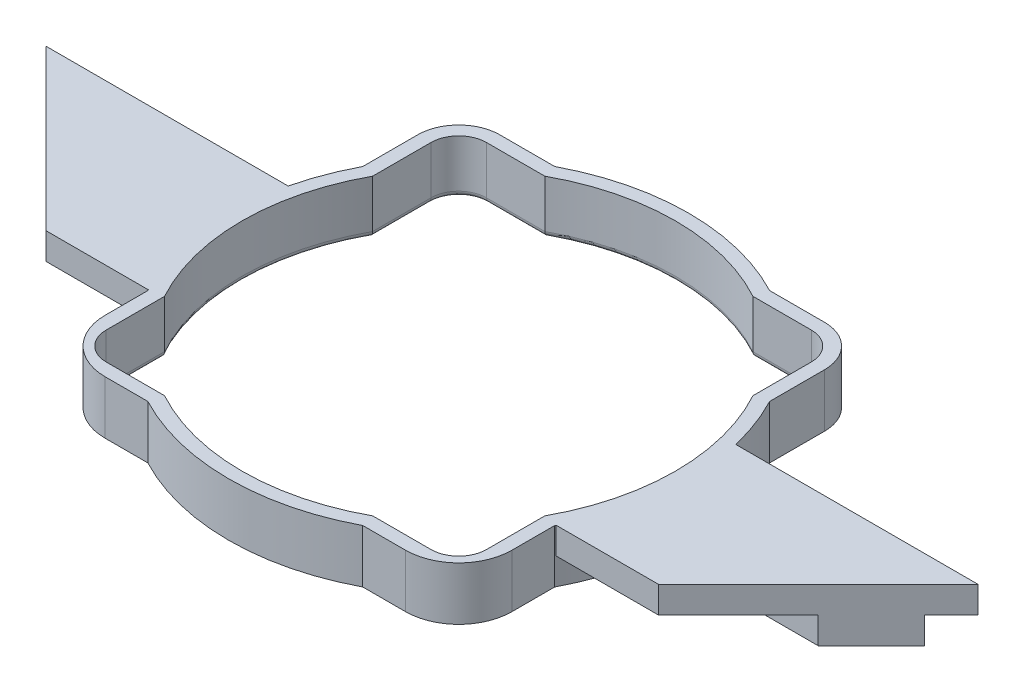
from build123d import *

# Parameters (mm, degrees)
SKETCH1_W           = 254
SKETCH1_H           = 152.4
BOSS_EXTRUDE1_DEPTH = 12.7
SKETCH4_OUTSIDE_W   = 315.296
SKETCH4_OUTSIDE_H   = 213.696
CUT_EXTRUDE1_DEPTH  = 13.7
BOSS_EXTRUDE2_DEPTH = 6.35
BOSS_EXTRUDE3_START = 6.35
BOSS_EXTRUDE3_DEPTH = 6.35
FILLET1_R           = 1.27
CUT_EXTRUDE3_DEPTH  = 13.7000001


with BuildPart() as part:
    # Sketch1 → Boss-Extrude1 (new body)
    with BuildSketch(Plane(origin=(0, 0, 0), x_dir=(1, 0, 0), z_dir=(0, 1, 0))):
        Rectangle(SKETCH1_W, SKETCH1_H)
    extrude(amount=BOSS_EXTRUDE1_DEPTH)

    # Sketch4 outside → Cut-Extrude1 (cut, through all)
    with BuildSketch(Plane.XZ):
        Rectangle(SKETCH4_OUTSIDE_W, SKETCH4_OUTSIDE_H)
        with BuildLine():
            Line((48.514, 25.621286072), (48.514, 38.735))
            ThreePointArc((48.514, 38.735), (45.649797213, 45.649797213), (38.735, 48.514))
            Line((38.735, 48.514), (25.621286072, 48.514))
            ThreePointArc((25.621286072, 48.514), (0, 54.864), (-25.621286072, 48.514))
            Line((-25.621286072, 48.514), (-38.735, 48.514))
            ThreePointArc((-38.735, 48.514), (-45.649797213, 45.649797213), (-48.514, 38.735))
            Line((-48.514, 38.735), (-48.514, 25.621286072))
            ThreePointArc((-48.514, 25.621286072), (-54.864, 0), (-48.514, -25.621286072))
            Line((-48.514, -25.621286072), (-48.514, -38.735))
            ThreePointArc((-48.514, -38.735), (-45.649797213, -45.649797213), (-38.735, -48.514))
            Line((-38.735, -48.514), (-25.621286072, -48.514))
            ThreePointArc((-25.621286072, -48.514), (0, -54.864), (25.621286072, -48.514))
            Line((25.621286072, -48.514), (38.735, -48.514))
            ThreePointArc((38.735, -48.514), (45.649797213, -45.649797213), (48.514, -38.735))
            Line((48.514, -38.735), (48.514, -25.621286072))
            ThreePointArc((48.514, -25.621286072), (54.864, 0), (48.514, 25.621286072))
        make_face(mode=Mode.SUBTRACT)
        with BuildLine():
            Line((45.339, 24.821921763), (45.339, 38.735))
            ThreePointArc((45.339, 38.735), (43.404733183, 43.404733183), (38.735, 45.339))
            Line((38.735, 45.339), (24.821921763, 45.339))
            ThreePointArc((24.821921763, 45.339), (0, 51.689), (-24.821921763, 45.339))
            Line((-24.821921763, 45.339), (-38.735, 45.339))
            ThreePointArc((-38.735, 45.339), (-43.404733183, 43.404733183), (-45.339, 38.735))
            Line((-45.339, 38.735), (-45.339, 24.821921763))
            ThreePointArc((-45.339, 24.821921763), (-51.689, 0), (-45.339, -24.821921763))
            Line((-45.339, -24.821921763), (-45.339, -38.735))
            ThreePointArc((-45.339, -38.735), (-43.404733183, -43.404733183), (-38.735, -45.339))
            Line((-38.735, -45.339), (-24.821921763, -45.339))
            ThreePointArc((-24.821921763, -45.339), (0, -51.689), (24.821921763, -45.339))
            Line((24.821921763, -45.339), (38.735, -45.339))
            ThreePointArc((38.735, -45.339), (43.404733183, -43.404733183), (45.339, -38.735))
            Line((45.339, -38.735), (45.339, -24.821921763))
            ThreePointArc((45.339, -24.821921763), (51.689, 0), (45.339, 24.821921763))
        make_face()
    extrude(amount=-CUT_EXTRUDE1_DEPTH, mode=Mode.SUBTRACT)

    # Sketch5 → Boss-Extrude2 (add)
    with BuildSketch(Plane(origin=(0, 0, 0), x_dir=(1, 0, 0), z_dir=(0, 1, 0))):
        with BuildLine():
            Line((54.495284163, 6.35), (104.775, 6.35))
            Line((104.775, 6.35), (92.075, -6.35))
            Line((92.075, -6.35), (54.495284163, -6.35))
            ThreePointArc((54.495284163, -6.35), (54.864, 0), (54.495284163, 6.35))
        make_face()
        with BuildLine():
            Line((-92.075, -6.35), (-54.495284163, -6.35))
            ThreePointArc((-54.495284163, -6.35), (-54.864, 0), (-54.495284163, 6.35))
            Line((-54.495284163, 6.35), (-104.775, 6.35))
            Line((-104.775, 6.35), (-92.075, -6.35))
        make_face()
    extrude(amount=BOSS_EXTRUDE2_DEPTH)

    # Sketch6 → Boss-Extrude3 (add)
    with BuildSketch(Plane(origin=(0, 0, 0), x_dir=(1, 0, 0), z_dir=(0, 1, 0)).offset(BOSS_EXTRUDE3_START)):
        with BuildLine():
            Line((53.373855922, 12.7), (111.125, 12.7))
            Line((111.125, 12.7), (73.025, -25.4))
            Line((73.025, -25.4), (48.630222043, -25.4))
            ThreePointArc((48.630222043, -25.4), (54.443644996, -6.778496559), (53.373855922, 12.7))
        make_face()
        with BuildLine():
            Line((-73.025, -25.4), (-48.630222043, -25.4))
            ThreePointArc((-48.630222043, -25.4), (-54.443644996, -6.778496559), (-53.373855922, 12.7))
            Line((-53.373855922, 12.7), (-111.125, 12.7))
            Line((-111.125, 12.7), (-73.025, -25.4))
        make_face()
    extrude(amount=BOSS_EXTRUDE3_DEPTH)

    # Fillet1
    fillet1_edges = [part.edges().sort_by_distance(p)[0] for p in [
        (51.689, 0, 0),
        (45.339, 0, 31.778460881),
        (43.404733183, 0, 43.404733183),
        (31.778460881, 0, 45.339),
        (0, 0, 51.689),
        (-31.778460881, 0, 45.339),
        (-43.404733183, 0, 43.404733183),
        (-45.339, 0, 31.778460881),
        (-51.689, 0, 0),
        (-45.339, 0, -31.778460881),
        (-43.404733183, 0, -43.404733183),
        (-31.778460881, 0, -45.339),
        (0, 0, -51.689),
        (31.778460881, 0, -45.339),
        (43.404733183, 0, -43.404733183),
        (45.339, 0, -31.778460881),
    ]]
    fillet(fillet1_edges, radius=FILLET1_R)

    # Sketch9 → Cut-Extrude3 (cut, through all)
    with BuildSketch(Plane(origin=(0, 12.7, 0), x_dir=(1, 0, 0), z_dir=(0, 1, 0))):
        with BuildLine():
            Line((38.735, -48.514), (35.814, -48.514))
            ThreePointArc((35.814, -48.514), (44.794256121, -44.794256121), (48.514, -35.814))
            Line((48.514, -35.814), (48.514, -38.735))
            ThreePointArc((48.514, -38.735), (45.649797213, -45.649797213), (38.735, -48.514))
        make_face()
        with BuildLine():
            Line((-48.514, -35.814), (-48.514, -38.735))
            ThreePointArc((-48.514, -38.735), (-45.649797213, -45.649797213), (-38.735, -48.514))
            Line((-38.735, -48.514), (-35.814, -48.514))
            ThreePointArc((-35.814, -48.514), (-44.794256121, -44.794256121), (-48.514, -35.814))
        make_face()
    extrude(amount=-CUT_EXTRUDE3_DEPTH, mode=Mode.SUBTRACT)


solid = part.part
